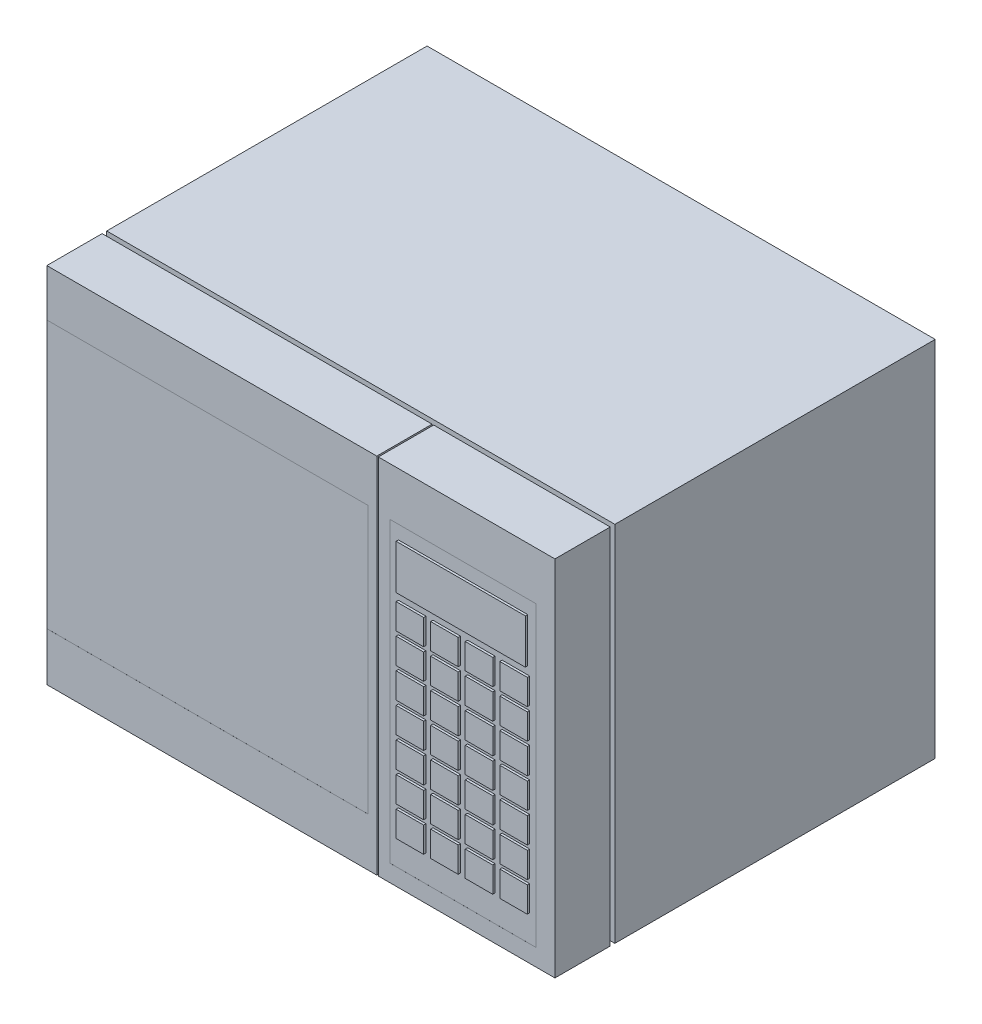
from build123d import *

# Parameters (mm, degrees)
SKETCH1_W           = 560
SKETCH1_H           = 400
BOSS_EXTRUDE1_DEPTH = 419.1
SKETCH2_W           = 509.762265323
SKETCH2_H           = 294.60835285
SKETCH2_W_2         = 160.630106896
SKETCH2_H_2         = 328.11637689
CUT_EXTRUDE1_DEPTH  = 0.0254
CUT_EXTRUDE2_START  = -60.96
SKETCH3_W           = 758.952
SKETCH3_H           = 400
SKETCH3_W_2         = 745.362874068
SKETCH3_H_2         = 373.171162969
CUT_EXTRUDE2_DEPTH  = 5.08
SKETCH5_W           = 30.340291286
SKETCH5_H           = 28.006422725
SKETCH5_W_2         = 142.365982185
SKETCH5_H_2         = 49.011239769
BOSS_EXTRUDE3_DEPTH = 2.54
SKETCH6_W           = 1.719763346
SKETCH6_H           = 400
CUT_EXTRUDE3_DEPTH  = 63.5


with BuildPart() as part:
    # Sketch1 → Boss-Extrude1 (new body)
    with BuildSketch(Plane.XY):
        with Locations((161.193919926, -4.872504675)):
            Rectangle(SKETCH1_W, SKETCH1_H)
    extrude(amount=BOSS_EXTRUDE1_DEPTH)

    # Sketch2 → Cut-Extrude1 (cut)
    with BuildSketch(Plane.XY.offset(419.1)):
        with Locations((-19.802766229, -4.093923129)):
            Rectangle(SKETCH2_W, SKETCH2_H)
        with Locations((339.761572352, -22.10119724)):
            Rectangle(SKETCH2_W_2, SKETCH2_H_2)
    extrude(amount=-CUT_EXTRUDE1_DEPTH, mode=Mode.SUBTRACT)

    # Sketch3 → Cut-Extrude2 (cut)
    with BuildSketch(Plane.XY.offset(419.1).offset(CUT_EXTRUDE2_START)):
        with Locations((61.717919926, -4.872504675)):
            Rectangle(SKETCH3_W, SKETCH3_H)
        with Locations((61.107514964, -10.347774784)):
            Rectangle(SKETCH3_W_2, SKETCH3_H_2, mode=Mode.SUBTRACT)
    extrude(amount=-CUT_EXTRUDE2_DEPTH, mode=Mode.SUBTRACT)

    # Sketch5 → Boss-Extrude3 (add)
    with BuildSketch(Plane.XY.offset(419.0746)):
        with Locations((321.924411259, 55.397530231)):
            Rectangle(SKETCH5_W, SKETCH5_H)
        with Locations((339.837256709, 102.463879533)):
            Rectangle(SKETCH5_W_2, SKETCH5_H_2)
        with Locations((283.824411259, 55.397530231)):
            Rectangle(SKETCH5_W, SKETCH5_H)
        with Locations((360.024411259, 55.397530231)):
            Rectangle(SKETCH5_W, SKETCH5_H)
        with Locations((398.124411259, 55.397530231)):
            Rectangle(SKETCH5_W, SKETCH5_H)
        with Locations((321.924411259, 22.377530231)):
            Rectangle(SKETCH5_W, SKETCH5_H)
        with Locations((360.024411259, 22.377530231)):
            Rectangle(SKETCH5_W, SKETCH5_H)
        with Locations((398.124411259, 22.377530231)):
            Rectangle(SKETCH5_W, SKETCH5_H)
        with Locations((321.924411259, -10.642469769)):
            Rectangle(SKETCH5_W, SKETCH5_H)
        with Locations((360.024411259, -10.642469769)):
            Rectangle(SKETCH5_W, SKETCH5_H)
        with Locations((398.124411259, -10.642469769)):
            Rectangle(SKETCH5_W, SKETCH5_H)
        with Locations((321.924411259, -43.66246977)):
            Rectangle(SKETCH5_W, SKETCH5_H)
        with Locations((360.024411259, -43.66246977)):
            Rectangle(SKETCH5_W, SKETCH5_H)
        with Locations((398.124411259, -43.66246977)):
            Rectangle(SKETCH5_W, SKETCH5_H)
        with Locations((321.924411259, -76.68246977)):
            Rectangle(SKETCH5_W, SKETCH5_H)
        with Locations((360.024411259, -76.68246977)):
            Rectangle(SKETCH5_W, SKETCH5_H)
        with Locations((398.124411259, -76.68246977)):
            Rectangle(SKETCH5_W, SKETCH5_H)
        with Locations((321.924411259, -109.702469769)):
            Rectangle(SKETCH5_W, SKETCH5_H)
        with Locations((360.024411259, -109.702469769)):
            Rectangle(SKETCH5_W, SKETCH5_H)
        with Locations((398.124411259, -109.702469769)):
            Rectangle(SKETCH5_W, SKETCH5_H)
        with Locations((321.924411259, -142.72246977)):
            Rectangle(SKETCH5_W, SKETCH5_H)
        with Locations((360.024411259, -142.72246977)):
            Rectangle(SKETCH5_W, SKETCH5_H)
        with Locations((398.124411259, -142.72246977)):
            Rectangle(SKETCH5_W, SKETCH5_H)
        with Locations((283.824411259, 22.377530231)):
            Rectangle(SKETCH5_W, SKETCH5_H)
        with Locations((283.824411259, -10.642469769)):
            Rectangle(SKETCH5_W, SKETCH5_H)
        with Locations((283.824411259, -43.66246977)):
            Rectangle(SKETCH5_W, SKETCH5_H)
        with Locations((283.824411259, -76.68246977)):
            Rectangle(SKETCH5_W, SKETCH5_H)
        with Locations((283.824411259, -109.702469769)):
            Rectangle(SKETCH5_W, SKETCH5_H)
        with Locations((283.824411259, -142.72246977)):
            Rectangle(SKETCH5_W, SKETCH5_H)
    extrude(amount=BOSS_EXTRUDE3_DEPTH)

    # Sketch6 → Cut-Extrude3 (cut)
    with BuildSketch(Plane.XY.offset(419.1)):
        with Locations((245.729481122, -4.872504675)):
            Rectangle(SKETCH6_W, SKETCH6_H)
    extrude(amount=-CUT_EXTRUDE3_DEPTH, mode=Mode.SUBTRACT)


solid = part.part
